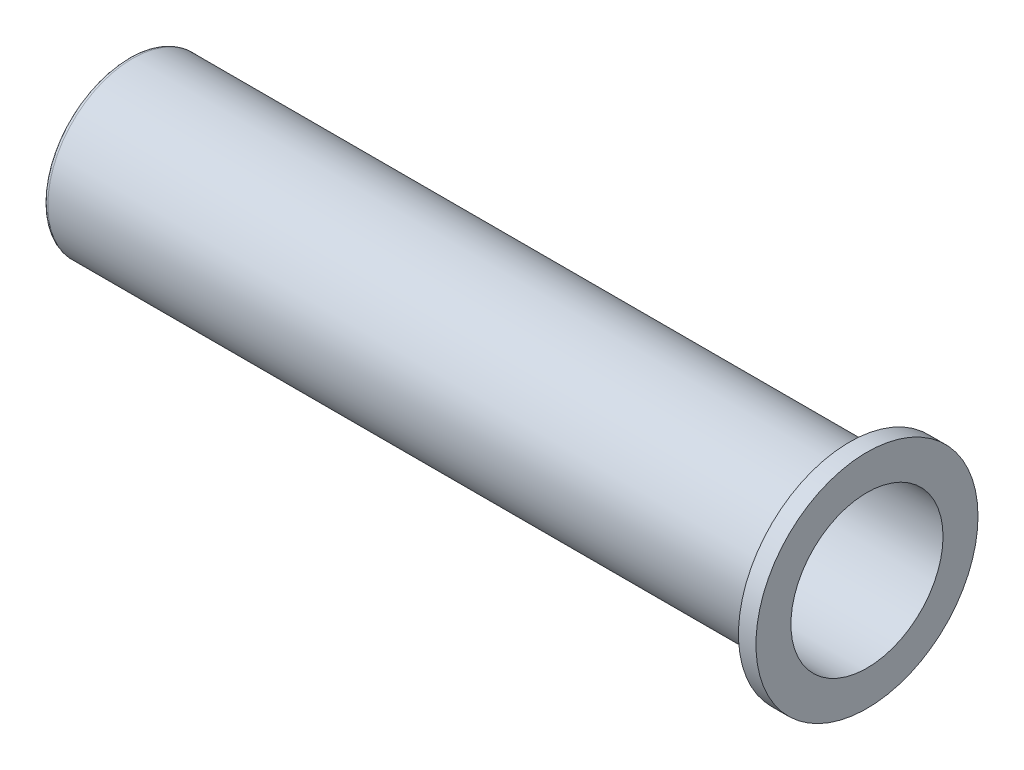
from build123d import *

# Parameters (mm, degrees)
SKETCH2_R           = 4.85
SKETCH2_R_2         = 2.75
BOSS_EXTRUDE1_DEPTH = 0.5
FILLET1_R           = 0.25


with BuildPart() as part:
    # Sketch1 → Revolve1 (revolve)
    with BuildSketch(Plane(origin=(0, 0, 0), x_dir=(1, 0, 0), z_dir=(0, 1, 0))):
        Polygon((-35, 4.35), (6.75, 4.35), (6.75, 6.35), (5.75, 6.35), (5.75, 4.85), (-35, 4.85), align=None)
    revolve(axis=Axis((0, 0, 0), (-1, 0, 0)))

    # Sketch2 → Boss-Extrude1 (add)
    with BuildSketch(Plane.ZY.offset(35)):
        Circle(SKETCH2_R)
        Circle(SKETCH2_R_2, mode=Mode.SUBTRACT)
    extrude(amount=BOSS_EXTRUDE1_DEPTH)

    # Fillet1
    fillet1_edges = [part.edges().sort_by_distance(p)[0] for p in [
        (-35.5, 0, -4.85),
        (-35, 0, 4.35),
    ]]
    fillet(fillet1_edges, radius=FILLET1_R)


solid = part.part
